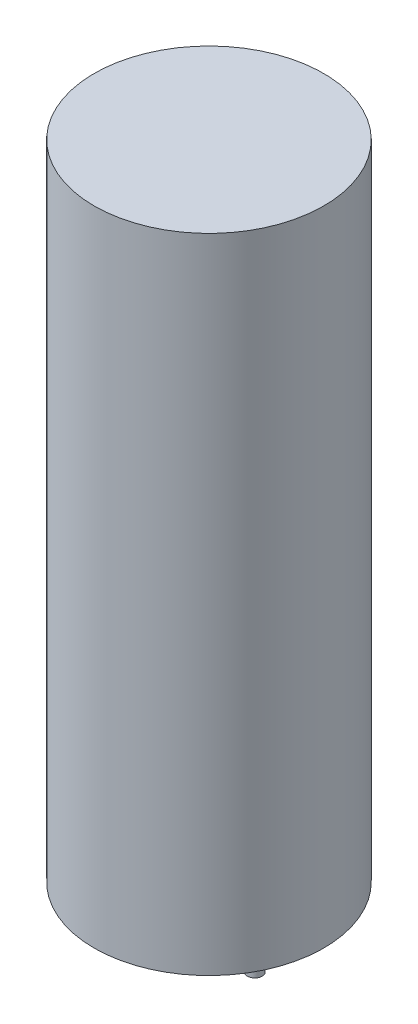
from build123d import *

# Parameters (mm, degrees)
SKETCH_1_R      = 0.4
EXTRUDE_2_DEPTH = 3
SKETCH_2_R      = 0.4
EXTRUDE_3_DEPTH = 3
SKETCH_3_R      = 6.25
EXTRUDE_4_DEPTH = 35


with BuildPart() as part:
    # 草图1 → 凸台-拉伸2 (new body)
    with BuildSketch(Plane(origin=(0, 0, 0), x_dir=(1, 0, 0), z_dir=(0, 1, 0))):
        with Locations((-2.5, 0)):
            Circle(SKETCH_1_R)
    extrude(amount=-EXTRUDE_2_DEPTH)



with BuildPart() as body_2:
    # 草图2 → 凸台-拉伸3 (new body)
    with BuildSketch(Plane(origin=(0, 0, 0), x_dir=(1, 0, 0), z_dir=(0, 1, 0))):
        with Locations((2.5, 0)):
            Circle(SKETCH_2_R)
    extrude(amount=-EXTRUDE_3_DEPTH)


with BuildPart() as part_1:
    add(part.part)

    add(body_2.part)  # 凸台-拉伸4 merges body 2
    # 草图3 → 凸台-拉伸4 (add)
    with BuildSketch(Plane(origin=(0, 0, 0), x_dir=(1, 0, 0), z_dir=(0, 1, 0))):
        Circle(SKETCH_3_R)
    extrude(amount=EXTRUDE_4_DEPTH)


solid = part_1.part
